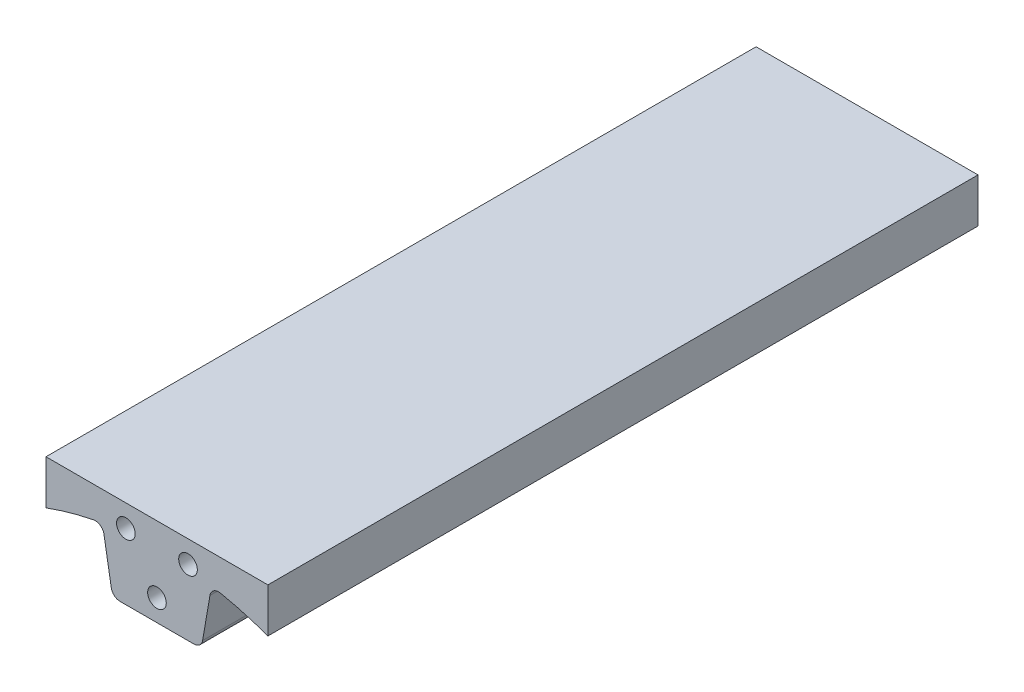
from build123d import *

# Parameters (mm, degrees)
BOSS_EXTRUDE1_DEPTH = 203.2
FILLET1_R           = 2.54
SKETCH2_R           = 2.667
CUT_EXTRUDE1_DEPTH  = 11.43


with BuildPart() as part:
    # Sketch1 → Boss-Extrude1 (new body)
    with BuildSketch(Plane.XY):
        with BuildLine():
            Line((-12.7, 73.846320157), (12.7, 73.846320157))
            Line((12.7, 73.846320157), (15.605843118, 90.742841512))
            ThreePointArc((15.605843118, 90.742841512), (23.776020133, 88.952270863), (31.75, 86.427675689))
            Line((31.75, 86.427675689), (31.75, 99.102275689))
            Line((31.75, 99.102275689), (-31.75, 99.102275689))
            Line((-31.75, 99.102275689), (-31.75, 86.427675689))
            ThreePointArc((-31.75, 86.427675689), (-23.776020133, 88.952270863), (-15.605843118, 90.742841512))
            Line((-15.605843118, 90.742841512), (-12.7, 73.846320157))
        make_face()
    extrude(amount=BOSS_EXTRUDE1_DEPTH)

    # Fillet1
    fillet1_edges = [part.edges().sort_by_distance(p)[0] for p in [
        (12.7, 73.846320157, 101.6),
        (-12.7, 73.846320157, 101.6),
        (-15.605843118, 90.742841512, 101.6),
        (15.605843118, 90.742841512, 101.6),
    ]]
    fillet(fillet1_edges, radius=FILLET1_R)

    # Sketch2 → Cut-Extrude1 (cut)
    with BuildSketch(Plane.XY.offset(203.2)):
        with Locations((-8.89, 92.752275689)):
            Circle(SKETCH2_R)
        with Locations((8.89, 92.752275689)):
            Circle(SKETCH2_R)
        with Locations((0, 80.052275689)):
            Circle(SKETCH2_R)
    extrude(amount=-CUT_EXTRUDE1_DEPTH, mode=Mode.SUBTRACT)


solid = part.part
